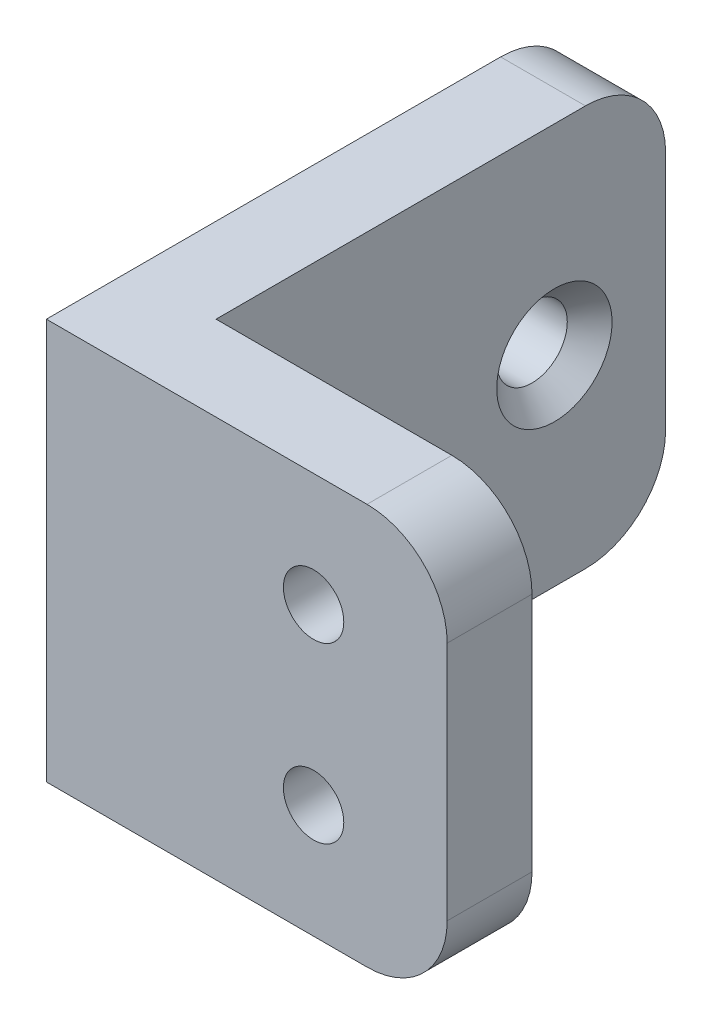
from build123d import *

# Parameters (mm, degrees)
BOSS_EXTRUDE1_DEPTH             = 7.5
F_2_CLEARANCE_HOLE1_D           = 2.2606
F_3_CLEARANCE_HOLE1_D           = 2.6416
F_3_CLEARANCE_HOLE1_CSINK_D     = 4.318
F_3_CLEARANCE_HOLE1_CSINK_ANGLE = 90
FILLET1_R                       = 3


with BuildPart() as part:
    # Sketch3 → Boss-Extrude1 (new body, symmetric)
    with BuildSketch(Plane(origin=(0, 0, 0), x_dir=(1, 0, 0), z_dir=(0, 1, 0))):
        Polygon((0, 0), (0, 20), (3.175, 20), (3.175, 3.175), (15, 3.175), (15, 0), align=None)
    extrude(amount=BOSS_EXTRUDE1_DEPTH, both=True)

    # #2 Clearance Hole1 (through all)
    with Locations(Plane.XY):
        with Locations((10, -3.25), (10, 3.25)):
            Hole(F_2_CLEARANCE_HOLE1_D / 2)

    # #3 Clearance Hole1 (through all)
    with Locations(Plane(origin=(3.175, 0, 0), x_dir=(0, 0, -1), z_dir=(1, 0, 0))):
        with Locations((7.3375, 0), (15.8375, 0)):
            CounterSinkHole(F_3_CLEARANCE_HOLE1_D / 2, F_3_CLEARANCE_HOLE1_CSINK_D / 2, counter_sink_angle=F_3_CLEARANCE_HOLE1_CSINK_ANGLE)

    # Fillet1
    fillet1_edges = [part.edges().sort_by_distance(p)[0] for p in [
        (1.5875, 7.5, -20),
        (1.5875, -7.5, -20),
        (15, -7.5, -1.5875),
        (15, 7.5, -1.5875),
    ]]
    fillet(fillet1_edges, radius=FILLET1_R)


solid = part.part
